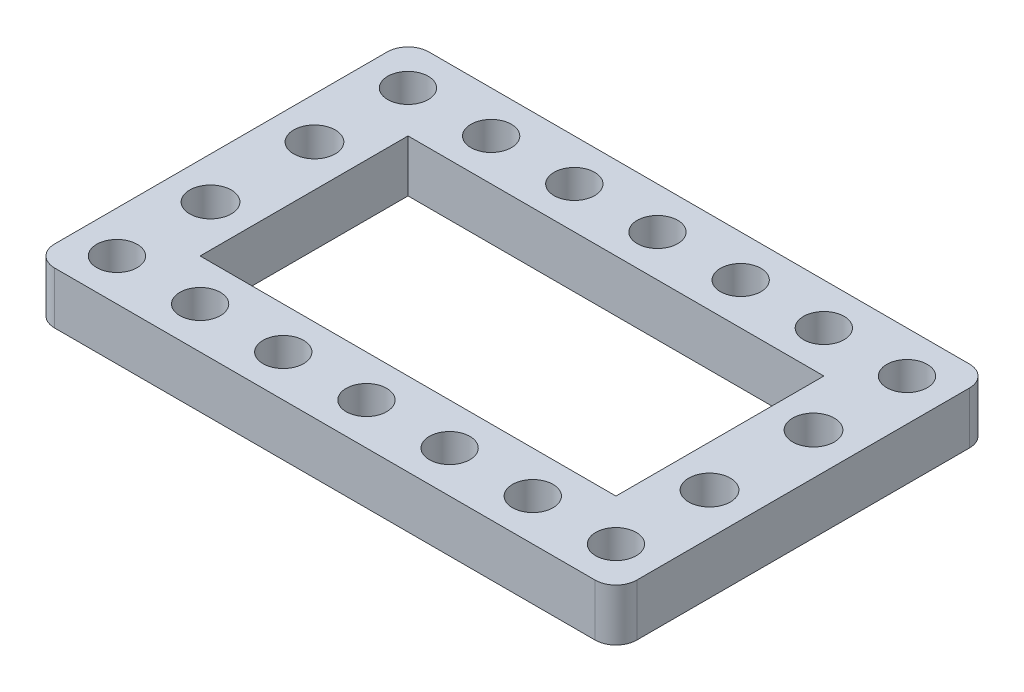
from build123d import *

# Parameters (mm, degrees)
BOSS_EXTRUDE1_DEPTH = 5
SKETCH2_R           = 1.95
SKETCH2_W           = 40
SKETCH2_H           = 20
CUT_EXTRUDE1_DEPTH  = 6
SKETCH4_W           = 22
SKETCH4_H           = 36
CUT_EXTRUDE2_DEPTH  = 10
FILLET1_R           = 2
FILLET2_R           = 2
FILLET3_R           = 2
FILLET4_R           = 2
SKETCH5_R           = 2
CUT_EXTRUDE3_DEPTH  = 6


with BuildPart() as part:
    # Sketch1 → Boss-Extrude1 (new body)
    with BuildSketch(Plane(origin=(0, 0, 0), x_dir=(1, 0, 0), z_dir=(0, 1, 0))):
        with BuildLine():
            Line((2, 0), (98, 0))
            ThreePointArc((98, 0), (99.414213562, -0.585786438), (100, -2))
            Line((100, -2), (100, -34))
            ThreePointArc((100, -34), (99.414213562, -35.414213562), (98, -36))
            Line((98, -36), (2, -36))
            ThreePointArc((2, -36), (0.585786438, -35.414213562), (0, -34))
            Line((0, -34), (0, -2))
            ThreePointArc((0, -2), (0.585786438, -0.585786438), (2, 0))
        make_face()
    extrude(amount=BOSS_EXTRUDE1_DEPTH)

    # Sketch2 → Cut-Extrude1 (cut, through all)
    with BuildSketch(Plane(origin=(0, 5, 0), x_dir=(1, 0, 0), z_dir=(0, 1, 0))):
        with Locations((90, -4.00475022)):
            Circle(SKETCH2_R)
        with Locations((82, -4.00475022)):
            Circle(SKETCH2_R)
        with Locations((18, -4.00475022)):
            Circle(SKETCH2_R)
        with Locations((26, -4.00475022)):
            Circle(SKETCH2_R)
        with Locations((34, -4.00475022)):
            Circle(SKETCH2_R)
        with Locations((42, -4.00475022)):
            Circle(SKETCH2_R)
        with Locations((50, -4.00475022)):
            Circle(SKETCH2_R)
        with Locations((58, -4.00475022)):
            Circle(SKETCH2_R)
        with Locations((66, -4.00475022)):
            Circle(SKETCH2_R)
        with Locations((74, -4.00475022)):
            Circle(SKETCH2_R)
        with Locations((90, -32)):
            Circle(SKETCH2_R)
        with Locations((82, -32)):
            Circle(SKETCH2_R)
        with Locations((18, -32)):
            Circle(SKETCH2_R)
        with Locations((26, -32)):
            Circle(SKETCH2_R)
        with Locations((34, -32)):
            Circle(SKETCH2_R)
        with Locations((42, -32)):
            Circle(SKETCH2_R)
        with Locations((50, -32)):
            Circle(SKETCH2_R)
        with Locations((58, -32)):
            Circle(SKETCH2_R)
        with Locations((66, -32)):
            Circle(SKETCH2_R)
        with Locations((74, -32)):
            Circle(SKETCH2_R)
        with Locations((50, -18)):
            Rectangle(SKETCH2_W, SKETCH2_H)
    extrude(amount=-CUT_EXTRUDE1_DEPTH, mode=Mode.SUBTRACT)

    # Sketch4 → Cut-Extrude2 (cut)
    with BuildSketch(Plane(origin=(0, 5, 0), x_dir=(1, 0, 0), z_dir=(0, 1, 0))):
        with Locations((89, -18)):
            Rectangle(SKETCH4_W, SKETCH4_H)
        with Locations((11, -18)):
            Rectangle(SKETCH4_W, SKETCH4_H)
    extrude(amount=-CUT_EXTRUDE2_DEPTH, mode=Mode.SUBTRACT)

    # Fillet1
    fillet1_edges = [part.edges().sort_by_distance(p)[0] for p in [
        (22, 2.5, 0),
    ]]
    fillet(fillet1_edges, radius=FILLET1_R)

    # Fillet2
    fillet2_edges = [part.edges().sort_by_distance(p)[0] for p in [
        (22, 2.5, 36),
    ]]
    fillet(fillet2_edges, radius=FILLET2_R)

    # Fillet3
    fillet3_edges = [part.edges().sort_by_distance(p)[0] for p in [
        (78, 2.5, 36),
    ]]
    fillet(fillet3_edges, radius=FILLET3_R)

    # Fillet4
    fillet4_edges = [part.edges().sort_by_distance(p)[0] for p in [
        (78, 2.5, 0),
    ]]
    fillet(fillet4_edges, radius=FILLET4_R)

    # Sketch5 → Cut-Extrude3 (cut, through all)
    with BuildSketch(Plane(origin=(0, 5, 0), x_dir=(1, 0, 0), z_dir=(0, 1, 0))):
        with Locations((74, -13)):
            Circle(SKETCH5_R)
        with Locations((74, -23)):
            Circle(SKETCH5_R)
        with Locations((26, -13)):
            Circle(SKETCH5_R)
        with Locations((26, -23)):
            Circle(SKETCH5_R)
    extrude(amount=-CUT_EXTRUDE3_DEPTH, mode=Mode.SUBTRACT)


solid = part.part
